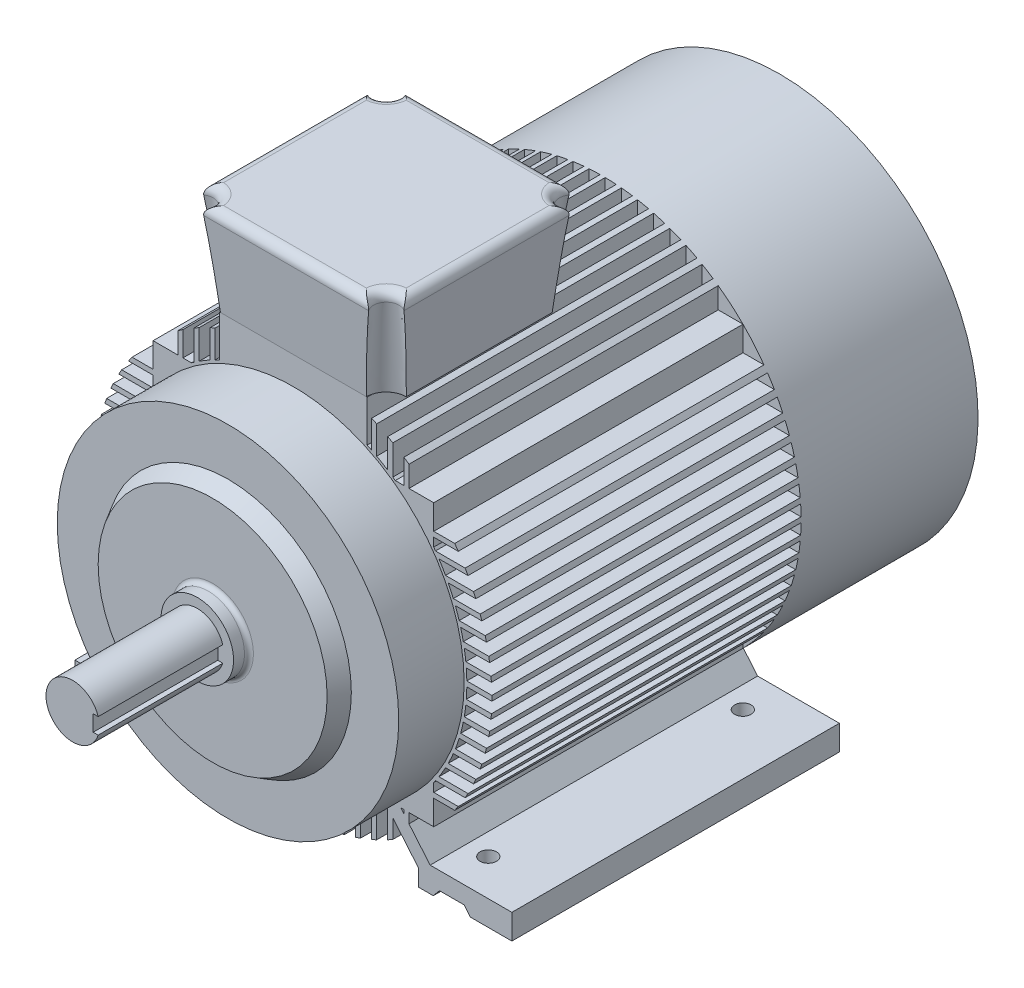
from build123d import *

# Parameters (mm, degrees)
FOOT_DEPTH                 = 184
FOOT_2_DEPTH               = 184
FOOT_HOLE_SECTION_R        = 9.25
FOOT_HOLE_DEPTH            = 28
MAIN_BODY_SECTION_R        = 194.870450474
MAIN_BODY_SECTION_R_2      = 173.263257281
MAIN_BODY_DEPTH            = 184
MAIN_BODY_DEPTH_BACK       = 234.671024
HEAT_START                 = -234.671024
HEAT_SINK_DEPTH            = 418.671024
HEAT_SINKS_COUNT           = 4
JB_BASE_SECTION_W          = 165.714285714
JB_BASE_SECTION_H          = 49.736742719
JB_BASE_DEPTH              = 165.714286
JB_DEPTH                   = 0.1
JB_OTHER_WAY_DEPTH         = 104
JB_OTHER_WAY_DRAFT         = -5
JB_FILLET_R                = 10
END_SHEILD_FRONT_SECTION_R = 191.870450474
END_SHEILD_FRONT_DEPTH     = 73.49458
SHAFT_DEPTH                = 140
SKETCH7_W                  = 368
SKETCH7_H                  = 28
BOSS_EXTRUDE1_DEPTH        = 30
SKETCH8_W                  = 368
SKETCH8_H                  = 28
BOSS_EXTRUDE2_DEPTH        = 30


with BuildPart() as part:
    # Foot Section → Foot (new, symmetric)
    with BuildSketch(Plane.XY):
        with BuildLine():
            Line((153.654023282, -197), (215.5, -197))
            Line((215.5, -197), (215.5, -225))
            Line((215.5, -225), (198.833333333, -225))
            Line((198.833333333, -225), (191.784896431, -216.6))
            Line((191.784896431, -216.6), (164.215103569, -216.6))
            Line((164.215103569, -216.6), (157.166666667, -225))
            Line((157.166666667, -225), (140.5, -225))
            Line((140.5, -225), (140.5, -206.215226727))
            Line((140.5, -206.215226727), (105.139212459, -164.073881137))
            ThreePointArc((105.139212459, -164.073881137), (111.811201711, -159.601840967), (118.293235741, -154.858654411))
            Line((118.293235741, -154.858654411), (153.654023282, -197))
        make_face()
    extrude(amount=FOOT_DEPTH, both=True)


with BuildPart() as body_2:
    # Foot Section → Foot 2 (new, symmetric)
    with BuildSketch(Plane.XY):
        with BuildLine():
            Line((-153.654023282, -197), (-118.293235741, -154.858654411))
            ThreePointArc((-118.293235741, -154.858654411), (-111.811201711, -159.601840967), (-105.139212459, -164.073881137))
            Line((-105.139212459, -164.073881137), (-140.5, -206.215226727))
            Line((-140.5, -206.215226727), (-140.5, -225))
            Line((-140.5, -225), (-157.166666667, -225))
            Line((-157.166666667, -225), (-164.215103569, -216.6))
            Line((-164.215103569, -216.6), (-191.784896431, -216.6))
            Line((-191.784896431, -216.6), (-198.833333333, -225))
            Line((-198.833333333, -225), (-215.5, -225))
            Line((-215.5, -225), (-215.5, -197))
            Line((-215.5, -197), (-153.654023282, -197))
        make_face()
    extrude(amount=FOOT_2_DEPTH, both=True)


with BuildPart() as foot_hole_tool:
    # Foot Hole Section → Foot Hole (new body)
    with BuildSketch(Plane(origin=(0, -225, 0), x_dir=(1, 0, 0), z_dir=(0, 1, 0))):
        with Locations(Location((-178, -143, 0), (0, 0, 90))):
            Circle(FOOT_HOLE_SECTION_R)
        with Locations(Location((-178, 143, 0), (0, 0, 90))):
            Circle(FOOT_HOLE_SECTION_R)
        with Locations(Location((178, 143, 0), (0, 0, 90))):
            Circle(FOOT_HOLE_SECTION_R)
        with Locations(Location((178, -143, 0), (0, 0, 90))):
            Circle(FOOT_HOLE_SECTION_R)
    extrude(amount=FOOT_HOLE_DEPTH)


with BuildPart() as part_1:
    add(part.part)

    # Foot Hole: cut by foot_hole_tool
    add(foot_hole_tool.part, mode=Mode.SUBTRACT)



with BuildPart() as body_2_1:
    add(body_2.part)

    # Foot Hole: cut by foot_hole_tool
    add(foot_hole_tool.part, mode=Mode.SUBTRACT)


with BuildPart() as part_2:
    add(part_1.part)

    add(body_2_1.part)  # Main Body merges body 2
    # Main Body Section → Main Body (add, two sides)
    with BuildSketch(Plane.XY) as main_body_sk:
        Circle(MAIN_BODY_SECTION_R)
        Circle(MAIN_BODY_SECTION_R_2, mode=Mode.SUBTRACT)
    extrude(amount=MAIN_BODY_DEPTH)
    extrude(main_body_sk.sketch, amount=-MAIN_BODY_DEPTH_BACK)

    # Heat Sink Section → Heat Sink (add)
    with BuildSketch(Plane.XY.offset(HEAT_START)):
        with BuildLine():
            Line((194.849477119, 2.858974359), (222.981672488, 2.858974359))
            ThreePointArc((222.981672488, 2.858974359), (223, 0), (222.981672488, -2.858974359))
            Line((222.981672488, -2.858974359), (194.849477119, -2.858974359))
            ThreePointArc((194.849477119, -2.858974359), (194.870450474, 0), (194.849477119, 2.858974359))
        make_face()
        with BuildLine():
            Line((194.269979557, 15.286186931), (222.475464915, 15.286186931))
            ThreePointArc((222.475464915, 15.286186931), (222.260429756, 18.146662637), (222.008617593, 21.004135649))
            Line((222.008617593, 21.004135649), (193.735176862, 21.004135649))
            ThreePointArc((193.735176862, 21.004135649), (194.023643111, 18.147131501), (194.269979557, 15.286186931))
        make_face()
        with BuildLine():
            Line((191.981346552, 33.431348222), (220.479806232, 33.431348222))
            ThreePointArc((220.479806232, 33.431348222), (220.026794033, 36.293386556), (219.536631452, 39.14929694))
            Line((219.536631452, 39.14929694), (190.897420143, 39.14929694))
            ThreePointArc((190.897420143, 39.14929694), (191.460730258, 36.294369221), (191.981346552, 33.431348222))
        make_face()
        with BuildLine():
            Line((187.921143394, 51.576509512), (216.953597957, 51.576509512))
            ThreePointArc((216.953597957, 51.576509512), (216.252768969, 54.440241671), (215.514141198, 57.29445823))
            Line((215.514141198, 57.29445823), (186.25744958, 57.29445823))
            ThreePointArc((186.25744958, 57.29445823), (187.111139686, 54.441839366), (187.921143394, 51.576509512))
        make_face()
        with BuildLine():
            Line((181.970824828, 69.721670802), (211.820415967, 69.721670802))
            ThreePointArc((211.820415967, 69.721670802), (210.855593445, 72.587317852), (209.852004533, 75.43961952))
            Line((209.852004533, 75.43961952), (179.675697507, 75.43961952))
            ThreePointArc((179.675697507, 75.43961952), (180.845861201, 72.589716588), (181.970824828, 69.721670802))
        make_face()
        with BuildLine():
            Line((173.936517977, 87.866832093), (204.959556542, 87.866832093))
            ThreePointArc((204.959556542, 87.866832093), (203.706176601, 90.734743151), (202.412669566, 93.584780811))
            Line((202.412669566, 93.584780811), (170.928000247, 93.584780811))
            ThreePointArc((170.928000247, 93.584780811), (172.455958775, 90.738276108), (173.936517977, 87.866832093))
        make_face()
        with BuildLine():
            Line((163.511313758, 106.011993383), (196.189850041, 106.011993383))
            ThreePointArc((196.189850041, 106.011993383), (194.611288941, 108.882717715), (192.990725265, 111.729942101))
            Line((192.990725265, 111.729942101), (159.658737644, 111.729942101))
            ThreePointArc((159.658737644, 111.729942101), (161.610316085, 108.888007617), (163.511313758, 106.011993383))
        make_face()
        with BuildLine():
            Line((157.684812205, 157.684812205), (157.684812205, 129.875103391))
            Line((157.684812205, 129.875103391), (181.277294549, 129.875103391))
            ThreePointArc((181.277294549, 129.875103391), (183.281140438, 127.03158489), (185.240386912, 124.157154673))
            Line((185.240386912, 124.157154673), (157.684812205, 124.157154673))
            Line((157.684812205, 124.157154673), (157.684812205, 114.4988754))
            ThreePointArc((157.684812205, 114.4988754), (137.794216983, 137.794216983), (114.4988754, 157.684812205))
            Line((114.4988754, 157.684812205), (157.684812205, 157.684812205))
        make_face()
        with BuildLine():
            Line((150.198180453, -124.157154673), (185.240386912, -124.157154673))
            ThreePointArc((185.240386912, -124.157154673), (183.281140438, -127.03158489), (181.277294549, -129.875103391))
            Line((181.277294549, -129.875103391), (145.282311336, -129.875103391))
            ThreePointArc((145.282311336, -129.875103391), (147.767905823, -127.039908992), (150.198180453, -124.157154673))
        make_face()
        with BuildLine():
            Line((163.511313758, -106.011993383), (196.189850041, -106.011993383))
            ThreePointArc((196.189850041, -106.011993383), (194.611288941, -108.882717715), (192.990725265, -111.729942101))
            Line((192.990725265, -111.729942101), (159.658737644, -111.729942101))
            ThreePointArc((159.658737644, -111.729942101), (161.610316085, -108.888007617), (163.511313758, -106.011993383))
        make_face()
        with BuildLine():
            Line((181.970824828, -69.721670802), (211.820415967, -69.721670802))
            ThreePointArc((211.820415967, -69.721670802), (210.855593445, -72.587317852), (209.852004533, -75.43961952))
            Line((209.852004533, -75.43961952), (179.675697507, -75.43961952))
            ThreePointArc((179.675697507, -75.43961952), (180.845861201, -72.589716588), (181.970824828, -69.721670802))
        make_face()
        with BuildLine():
            Line((187.921143394, -51.576509512), (216.953597957, -51.576509512))
            ThreePointArc((216.953597957, -51.576509512), (216.252768969, -54.440241671), (215.514141198, -57.29445823))
            Line((215.514141198, -57.29445823), (186.25744958, -57.29445823))
            ThreePointArc((186.25744958, -57.29445823), (187.111139686, -54.441839366), (187.921143394, -51.576509512))
        make_face()
        with BuildLine():
            Line((191.981346552, -33.431348222), (220.479806232, -33.431348222))
            ThreePointArc((220.479806232, -33.431348222), (220.026794033, -36.293386556), (219.536631452, -39.14929694))
            Line((219.536631452, -39.14929694), (190.897420143, -39.14929694))
            ThreePointArc((190.897420143, -39.14929694), (191.460730258, -36.294369221), (191.981346552, -33.431348222))
        make_face()
        with BuildLine():
            Line((173.936517977, -87.866832093), (204.959556542, -87.866832093))
            ThreePointArc((204.959556542, -87.866832093), (203.706176601, -90.734743151), (202.412669566, -93.584780811))
            Line((202.412669566, -93.584780811), (170.928000247, -93.584780811))
            ThreePointArc((170.928000247, -93.584780811), (172.455958775, -90.738276108), (173.936517977, -87.866832093))
        make_face()
        with BuildLine():
            Line((194.269979557, -15.286186931), (222.475464915, -15.286186931))
            ThreePointArc((222.475464915, -15.286186931), (222.260429756, -18.146662637), (222.008617593, -21.004135649))
            Line((222.008617593, -21.004135649), (193.735176862, -21.004135649))
            ThreePointArc((193.735176862, -21.004135649), (194.023643111, -18.147131501), (194.269979557, -15.286186931))
        make_face()
    heat_sink = extrude(amount=HEAT_SINK_DEPTH)

    # Heat Sinks: Heat Sink ×4 about axis
    heat_sinks_axis = Axis((0, 0, 0), (0, 0, 1))
    for i in range(1, HEAT_SINKS_COUNT):
        add(heat_sink.rotate(heat_sinks_axis, i * 360 / HEAT_SINKS_COUNT))

    # JB Base Section → JB Base (add)
    with BuildSketch(Plane.XY.offset(184)):
        with Locations((0, 198.131628641)):
            Rectangle(JB_BASE_SECTION_W, JB_BASE_SECTION_H)
    extrude(amount=-JB_BASE_DEPTH)

    # JB Section → JB (add)
    with BuildSketch(Plane(origin=(0, 223, 0), x_dir=(1, 0, 0), z_dir=(0, 1, 0))):
        with BuildLine():
            ThreePointArc((-81.948387097, 24.8), (-88.524312268, 8.924312268), (-104.4, 2.348387097))
            Line((-104.4, 2.348387097), (-104.4, -161.548387097))
            ThreePointArc((-104.4, -161.548387097), (-88.524312268, -168.124312268), (-81.948387097, -184))
            Line((-81.948387097, -184), (81.948387097, -184))
            ThreePointArc((81.948387097, -184), (88.524312268, -168.124312268), (104.4, -161.548387097))
            Line((104.4, -161.548387097), (104.4, 2.348387097))
            ThreePointArc((104.4, 2.348387097), (88.524312268, 8.924312268), (81.948387097, 24.8))
            Line((81.948387097, 24.8), (-81.948387097, 24.8))
        make_face()
    extrude(amount=-JB_DEPTH)


with BuildPart() as jb_other_way_tool:
    # JB Section → JB other way (with draft: the straight prism first)
    with BuildSketch(Plane(origin=(0, 223, 0), x_dir=(1, 0, 0), z_dir=(0, 1, 0))):
        with BuildLine():
            ThreePointArc((-81.948387097, 24.8), (-88.524312268, 8.924312268), (-104.4, 2.348387097))
            Line((-104.4, 2.348387097), (-104.4, -161.548387097))
            ThreePointArc((-104.4, -161.548387097), (-88.524312268, -168.124312268), (-81.948387097, -184))
            Line((-81.948387097, -184), (81.948387097, -184))
            ThreePointArc((81.948387097, -184), (88.524312268, -168.124312268), (104.4, -161.548387097))
            Line((104.4, -161.548387097), (104.4, 2.348387097))
            ThreePointArc((104.4, 2.348387097), (88.524312268, 8.924312268), (81.948387097, 24.8))
            Line((81.948387097, 24.8), (-81.948387097, 24.8))
        make_face()
    extrude(amount=JB_OTHER_WAY_DEPTH)
    # JB other way: the draft: its side faces are tilted about the plane it starts from
    jb_other_way_sides = [jb_other_way_tool.faces().sort_by_distance(p)[0] for p in [
        (88.524312268, 275, -8.924312268),
        (0, 275, -24.8),
        (-88.524312268, 275, -8.924312268),
        (-104.4, 275, 79.6),
        (-88.524312268, 275, 168.124312268),
        (0, 275, 184),
        (88.524312268, 275, 168.124312268),
        (104.4, 275, 79.6),
    ]]
    draft(jb_other_way_sides, Plane(origin=(0, 223, 0), x_dir=(1, 0, 0), z_dir=(0, 1, 0)), JB_OTHER_WAY_DRAFT)


with BuildPart() as part_3:
    add(part_2.part)

    # JB other way: add jb_other_way_tool
    add(jb_other_way_tool.part)

    # JB Fillet
    jb_fillet_edges = [part_3.edges().sort_by_distance(p)[0] for p in [
        (-94.958150302, 327, -15.358150302),
        (94.958150302, 327, -15.358150302),
        (-94.958150302, 327, 174.558150302),
        (94.958150302, 327, 174.558150302),
        (0, 327, -33.898821007),
        (-113.498821007, 327, 79.6),
        (0, 327, 193.098821007),
        (113.498821007, 327, 79.6),
    ]]
    fillet(jb_fillet_edges, radius=JB_FILLET_R)

    # Back Cover Section → Back Cover (revolve)
    with BuildSketch(Plane(origin=(0, 0, 0), x_dir=(0, 0, -1), z_dir=(1, 0, 0))):
        Polygon((163.5, 223), (362.326675096, 223), (380, 157.042253521), (380, 0), (163.5, 0), align=None)
    revolve(axis=Axis((0, 0, -380), (0, 0, 1)))

    # End Sheild (Front) Section → End Sheild (Front) (add)
    with BuildSketch(Plane.XY.offset(184)):
        Circle(END_SHEILD_FRONT_SECTION_R)
    extrude(amount=END_SHEILD_FRONT_DEPTH)

    # Sketch3 → End Sheild (Front) Seal Housing (revolve)
    with BuildSketch(Plane(origin=(0, 0, 0), x_dir=(0, 0, -1), z_dir=(1, 0, 0)), mode=Mode.PRIVATE) as end_sheild_front_seal_housing_sk:
        with BuildLine():
            Line((-292, 40.76663), (-279.74729, 40.76663))
            ThreePointArc((-279.74729, 40.76663), (-276.211756094, 42.231096094), (-274.74729, 45.76663))
            Line((-274.74729, 45.76663), (-274.74729, 128.647023237))
            Line((-274.74729, 128.647023237), (-257.49458, 138.60788))
            Line((-257.49458, 138.60788), (-257.49458, 0))
            Line((-257.49458, 0), (-292, 0))
            Line((-292, 0), (-292, 40.76663))
        make_face()
    revolve(end_sheild_front_seal_housing_sk.sketch.rotate(Axis((0, 0, -530.857604627), (0, 0, 1)), 90), axis=Axis((0, 0, -530.857604627), (0, 0, 1)))

    # Shaft Section → Shaft (add)
    with BuildSketch(Plane.XY.offset(292)):
        with BuildLine():
            Line((28.618176043, 9), (23, 9))
            Line((23, 9), (23, -9))
            Line((23, -9), (28.618176043, -9))
            ThreePointArc((28.618176043, -9), (-30, 0), (28.618176043, 9))
        make_face()
    extrude(amount=SHAFT_DEPTH)

    # Sketch7 → Boss-Extrude1 (add)
    with BuildSketch(Plane(origin=(215.5, 0, 0), x_dir=(0, 0, -1), z_dir=(1, 0, 0))):
        with Locations((0, -211)):
            Rectangle(SKETCH7_W, SKETCH7_H)
    extrude(amount=BOSS_EXTRUDE1_DEPTH)

    # Sketch8 → Boss-Extrude2 (add)
    with BuildSketch(Plane.ZY.offset(215.5)):
        with Locations((0, -211)):
            Rectangle(SKETCH8_W, SKETCH8_H)
    extrude(amount=BOSS_EXTRUDE2_DEPTH)


solid = part_3.part
